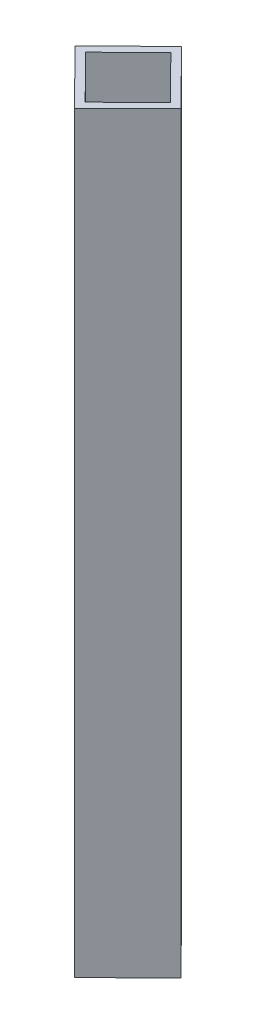
from build123d import *

# Parameters (mm, degrees)
EXTRUDE_THIN1_DEPTH = 1000


with BuildPart() as part:
    # Sketch1 → Extrude-Thin1 (new body)
    with BuildSketch(Plane(origin=(0, 0, 0), x_dir=(1, 0, 0), z_dir=(0, 1, 0))):
        Polygon((-71.177075898, 0.942127254), (0, 71.183310805), (71.177075898, -0.942127254), (0, -71.183310805), align=None)
        Polygon((-57.035249953, 0.84853802), (-0.093589235, 57.04148486), (57.035249953, -0.84853802), (0.093589235, -57.04148486), align=None, mode=Mode.SUBTRACT)
    extrude(amount=EXTRUDE_THIN1_DEPTH)


solid = part.part
